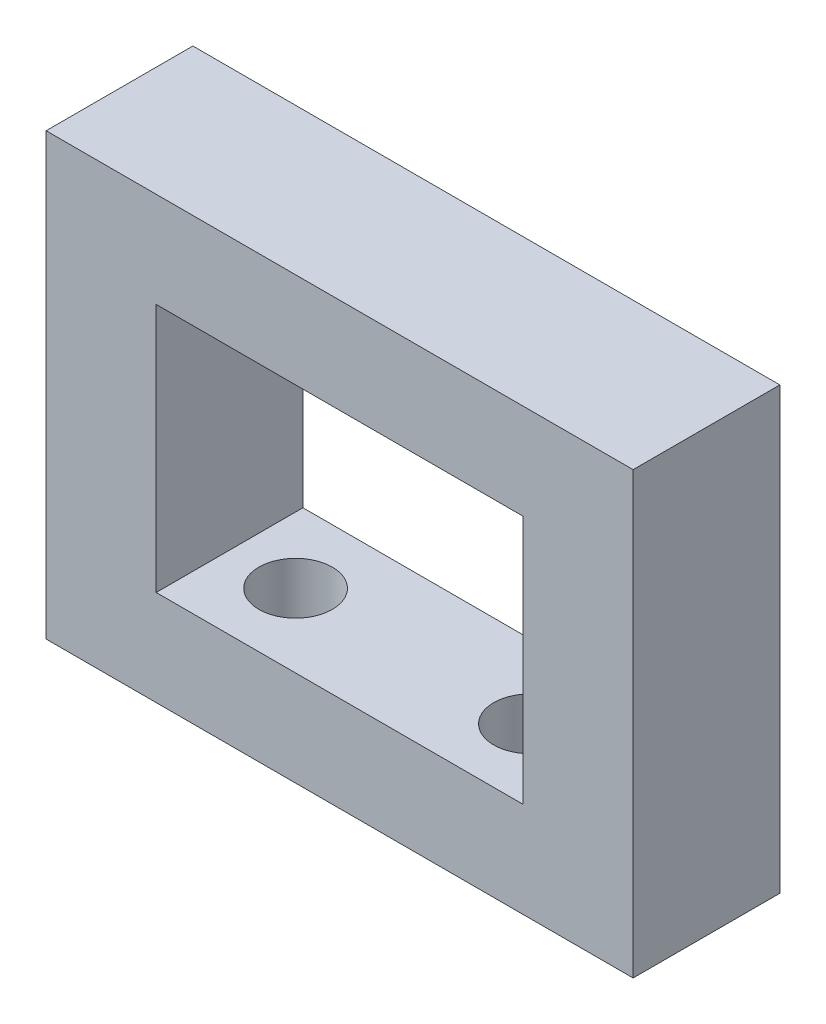
from build123d import *

# Parameters (mm, degrees)
SKETCH_1_W          = 20
SKETCH_1_H          = 15
EXTRUDE_1_DEPTH     = 2.5
SKETCH_2_W          = 12.5
SKETCH_2_H          = 8.5
CUT_EXTRUDE_1_DEPTH = 6
CUT_EXTRUDE_2_REACH = 17
SKETCH_4_R          = 1.25


with BuildPart() as part:
    # 草圖1 → 填料-伸長1 (new body, symmetric)
    with BuildSketch(Plane.XY):
        Rectangle(SKETCH_1_W, SKETCH_1_H)
    extrude(amount=EXTRUDE_1_DEPTH, both=True)

    # 草圖2 → 除料-伸長1 (cut, through all)
    with BuildSketch(Plane.XY.offset(2.5)):
        Rectangle(SKETCH_2_W, SKETCH_2_H)
    extrude(amount=-CUT_EXTRUDE_1_DEPTH, mode=Mode.SUBTRACT)

    # 草圖4 → 除料-伸長2 (cut, up to next)
    with BuildSketch(Plane.XZ.offset(7.5), mode=Mode.PRIVATE) as cut_extrude_2_sk1:
        with Locations((-4, 0)):
            Circle(SKETCH_4_R)
    cut_extrude_2_tool1 = extrude(cut_extrude_2_sk1.sketch, amount=-CUT_EXTRUDE_2_REACH, mode=Mode.PRIVATE) & part.part
    add(cut_extrude_2_tool1.solids().sort_by_distance((-4, -7.5, 0))[0], mode=Mode.SUBTRACT)
    # 草圖4 → 除料-伸長2 (cut, up to next)
    with BuildSketch(Plane.XZ.offset(7.5), mode=Mode.PRIVATE) as cut_extrude_2_sk2:
        with Locations((4, 0)):
            Circle(SKETCH_4_R)
    cut_extrude_2_tool2 = extrude(cut_extrude_2_sk2.sketch, amount=-CUT_EXTRUDE_2_REACH, mode=Mode.PRIVATE) & part.part
    add(cut_extrude_2_tool2.solids().sort_by_distance((4, -7.5, 0))[0], mode=Mode.SUBTRACT)


solid = part.part
